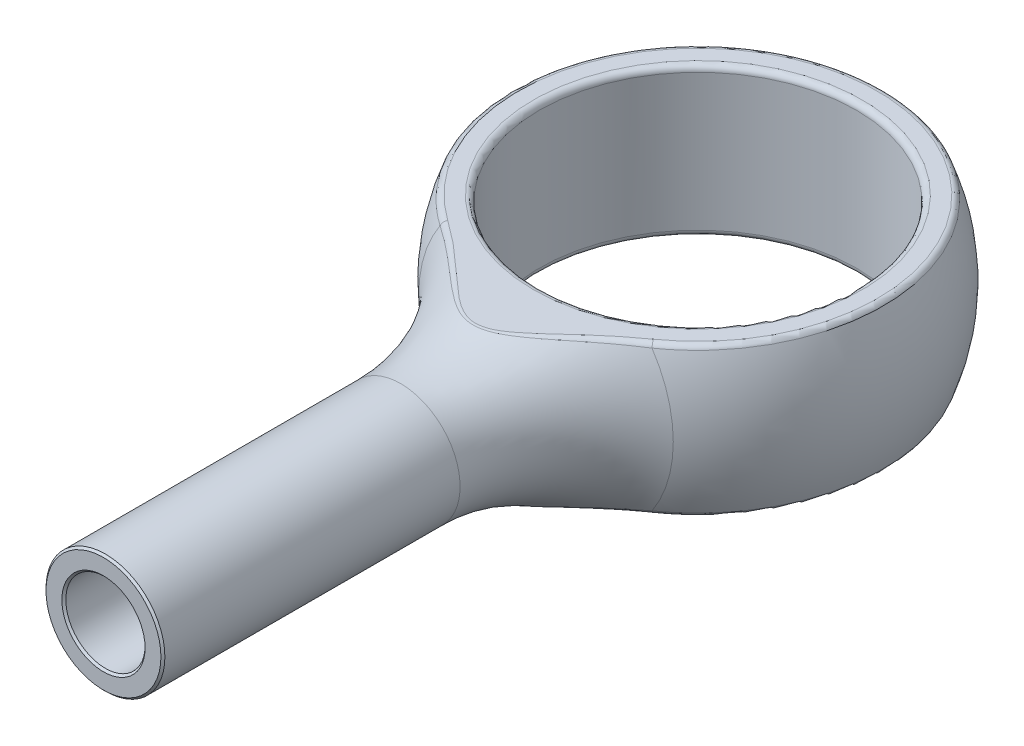
from build123d import *

# Parameters (mm, degrees)
CUT_EXTRUDE1_DEPTH      = 10
CUT_EXTRUDE1_DEPTH_BACK = 10
CUT_EXTRUDE2_DEPTH      = 10
CUT_EXTRUDE2_DEPTH_BACK = 10
SKETCH4_R               = 4
FILLET1_R               = 0.15
SKETCH5_R               = 1
CUT_EXTRUDE3_DEPTH      = 5
CHAMFER1_SIZE           = 0.05


with BuildPart() as part:
    # Sketch2 → Revolve1 (revolve)
    with BuildSketch(Plane(origin=(0, 0, 0), x_dir=(1, 0, 0), z_dir=(0, 1, 0))):
        with BuildLine():
            Line((-1.5, -15), (0, -15))
            Line((0, -15), (0, 5))
            ThreePointArc((0, 5), (-4.698967117, 1.708715315), (-3.211678832, -3.832116788))
            ThreePointArc((-3.211678832, -3.832116788), (-1.948980687, -5.476190987), (-1.5, -7.5))
            Line((-1.5, -7.5), (-1.5, -15))
        make_face()
    revolve(axis=Axis((0, 0, -5), (0, 0, 1)))

    # Sketch3 → Cut-Extrude1 (cut, two sides: drawn at the far end of the back side and taken through both)
    with BuildSketch(Plane(origin=(0, 0, 0), x_dir=(0, 0, -1), z_dir=(1, 0, 0)).offset(-CUT_EXTRUDE1_DEPTH_BACK)):
        with BuildLine():
            Line((-6.914251905, 1.875), (13.74921602, 1.875))
            Line((13.74921602, 1.875), (13.74921602, 11.382138009))
            Line((13.74921602, 11.382138009), (-22.068346047, 11.382138009))
            Line((-22.068346047, 11.382138009), (-9.782134087, 2.779239779))
            ThreePointArc((-9.782134087, 2.779239779), (-8.417780903, 2.106415246), (-6.914251905, 1.875))
        make_face()
        with BuildLine():
            Line((13.74921602, -11.382138009), (-22.068346047, -11.382138009))
            Line((-22.068346047, -11.382138009), (-9.782134087, -2.779239779))
            ThreePointArc((-9.782134087, -2.779239779), (-8.417780903, -2.106415246), (-6.914251905, -1.875))
            Line((-6.914251905, -1.875), (13.74921602, -1.875))
            Line((13.74921602, -1.875), (13.74921602, -11.382138009))
        make_face()
    extrude(amount=CUT_EXTRUDE1_DEPTH + CUT_EXTRUDE1_DEPTH_BACK, mode=Mode.SUBTRACT)

    # Sketch4 → Cut-Extrude2 (cut, two sides: drawn at the far end of the back side and taken through both)
    with BuildSketch(Plane(origin=(0, 0, 0), x_dir=(1, 0, 0), z_dir=(0, 1, 0)).offset(-CUT_EXTRUDE2_DEPTH_BACK)):
        Circle(SKETCH4_R)
    extrude(amount=CUT_EXTRUDE2_DEPTH + CUT_EXTRUDE2_DEPTH_BACK, mode=Mode.SUBTRACT)

    # Fillet1
    fillet1_edges = [part.edges().sort_by_distance(p)[0] for p in [
        (1e-09, -1.875, 5.642942998),
        (0, 1.875, -4.635124054),
        (-4, 1.875, 0),
        (-4, -1.875, 0),
        (0, -1.875, -4.635124054),
        (-1e-09, 1.875, 5.642942998),
    ]]
    fillet(fillet1_edges, radius=FILLET1_R)

    # Sketch5 → Cut-Extrude3 (cut)
    with BuildSketch(Plane.XY.offset(15)):
        Circle(SKETCH5_R)
    extrude(amount=-CUT_EXTRUDE3_DEPTH, mode=Mode.SUBTRACT)

    # Chamfer1
    chamfer1_edges = [part.edges().sort_by_distance(p)[0] for p in [
        (1.5, 0, 15),
        (-1, 0, 15),
    ]]
    chamfer(chamfer1_edges, length=CHAMFER1_SIZE)


solid = part.part
